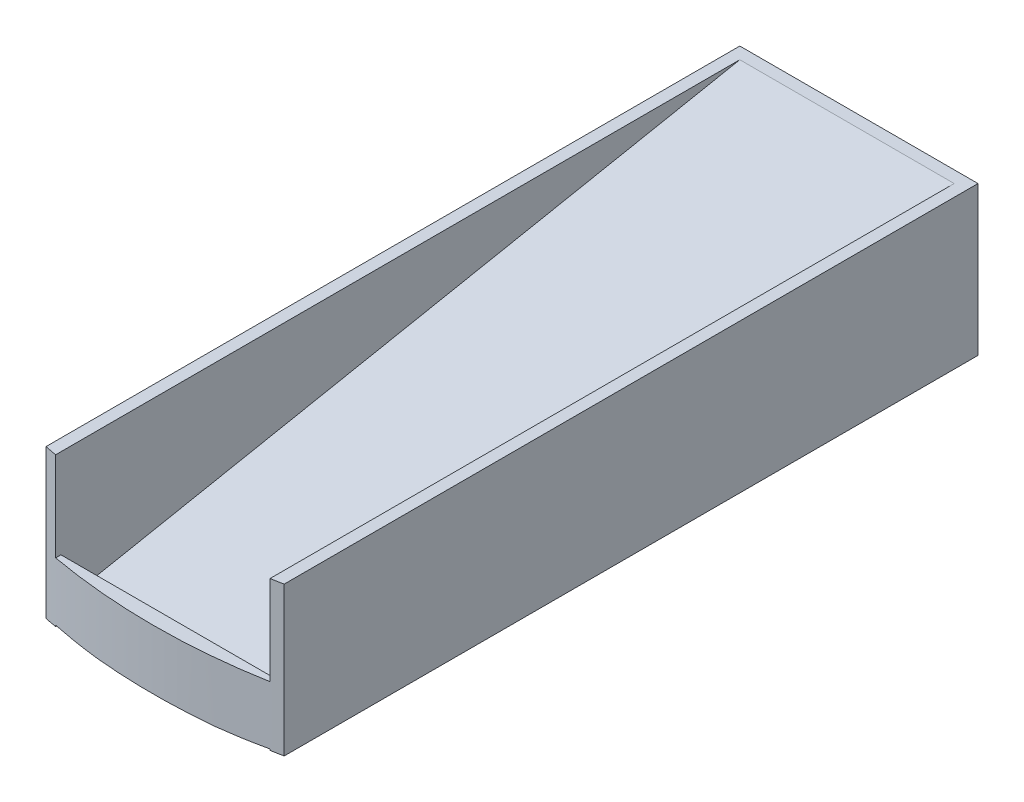
from build123d import *

# Parameters (mm, degrees)
SKETCH1_W           = 40
SKETCH1_H           = 25
BOSS_EXTRUDE1_DEPTH = 60
CUT_EXTRUDE3_DEPTH  = 18
SKETCH6_W           = 36
SKETCH6_H           = 8
BOSS_EXTRUDE2_DEPTH = 4
SKETCH7_R           = 500
SKETCH7_R_2         = 101.5
CUT_EXTRUDE4_DEPTH  = 26


with BuildPart() as part:
    # Sketch1 → Boss-Extrude1 (new body, symmetric)
    with BuildSketch(Plane.XY):
        Rectangle(SKETCH1_W, SKETCH1_H)
    extrude(amount=BOSS_EXTRUDE1_DEPTH, both=True)

    # Sketch4 → Cut-Extrude3 (cut, symmetric)
    with BuildSketch(Plane(origin=(0, 0, 0), x_dir=(0, 0, -1), z_dir=(1, 0, 0))):
        Polygon((-60, -10.5), (58, 12.5), (-60, 12.5), align=None)
        Polygon((-58, -12.5), (60, 10.5), (60, -12.5), align=None)
    extrude(amount=CUT_EXTRUDE3_DEPTH, both=True, mode=Mode.SUBTRACT)

    # Sketch6 → Boss-Extrude2 (add)
    with BuildSketch(Plane.XY.offset(60)):
        with Locations((0, -6.5)):
            Rectangle(SKETCH6_W, SKETCH6_H)
    extrude(amount=-BOSS_EXTRUDE2_DEPTH)

    # Sketch7 → Cut-Extrude4 (cut, through all)
    with BuildSketch(Plane(origin=(0, 12.5, 0), x_dir=(1, 0, 0), z_dir=(0, 1, 0))):
        with Locations((0, 43)):
            Circle(SKETCH7_R)
        with Locations((0, 43)):
            Circle(SKETCH7_R_2, mode=Mode.SUBTRACT)
    extrude(amount=-CUT_EXTRUDE4_DEPTH, mode=Mode.SUBTRACT)


solid = part.part
